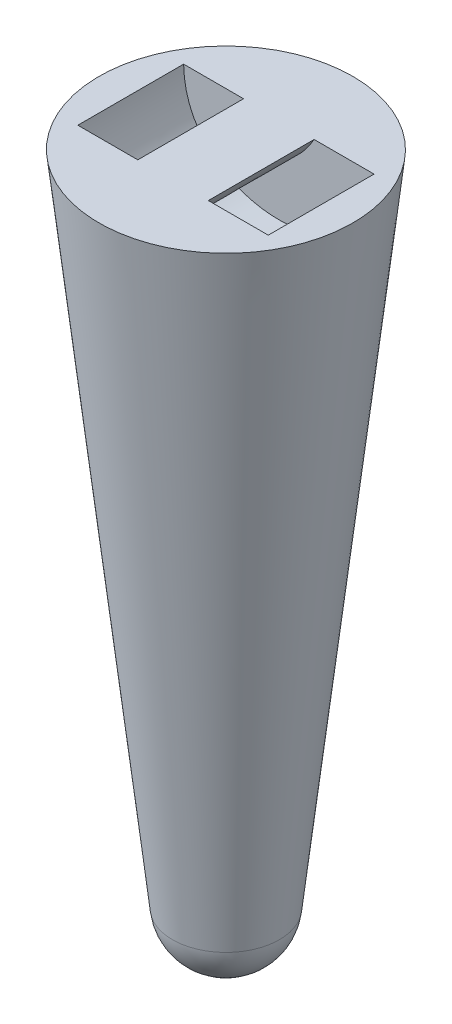
from build123d import *

# Parameters (mm, degrees)
ENL_V_MAT_EXTRU_1_DEPTH      = 7.5
ENL_V_MAT_EXTRU_1_DEPTH_BACK = 7.5
BOSS_EXTRU_1_REACH           = 27.5
ECHELLE1_SCALE               = 1.8


with BuildPart() as part:
    # Esquisse1 → R_volution1 (revolve)
    with BuildSketch(Plane.XY):
        with BuildLine():
            Line((0, 0), (0, 100))
            Line((0, 100), (-18, 100))
            Line((-18, 100), (-7.593007693, 6.792401612))
            ThreePointArc((-7.593007693, 6.792401612), (-5.093880777, 1.945904787), (0, 0))
        make_face()
    revolve(axis=Axis((0, 0, 0), (0, 1, 0)))

    # Esquisse2 → Enl_v. mat.-Extru.1 (cut, two sides)
    with BuildSketch(Plane.XY) as enl_v_mat_extru_1_sk:
        with BuildLine():
            Line((-13.5, 100), (13.5, 100))
            add(Edge.make_bspline(
                [(-13.5, 100), (-13.291113541, 83.520875666), (13.291113541, 83.520875666), (13.5, 100)],
                knots=[0, 0, 0, 0, 1, 1, 1, 1], degree=3))
        make_face()
    extrude(amount=ENL_V_MAT_EXTRU_1_DEPTH, mode=Mode.SUBTRACT)
    extrude(enl_v_mat_extru_1_sk.sketch, amount=-ENL_V_MAT_EXTRU_1_DEPTH_BACK, mode=Mode.SUBTRACT)

    # Esquisse3 → Boss.-Extru.1 (add, up to next)
    with BuildSketch(Plane.XY.offset(-7.5), mode=Mode.PRIVATE) as boss_extru_1_sk1:
        with BuildLine():
            Line((-5, 100), (5, 100))
            add(Edge.make_bspline(
                [(-5, 100), (0, 91.498247822), (5, 100)],
                knots=[0, 0, 0, 1, 1, 1], degree=2))
        make_face()
    boss_extru_1_tool1 = extrude(boss_extru_1_sk1.sketch, amount=BOSS_EXTRU_1_REACH, mode=Mode.PRIVATE) - part.part
    add(boss_extru_1_tool1.solids().sort_by_distance((0, 98.29965, -7.5))[0])


with BuildPart() as part_1:
    # Echelle1: scaled about (-4e-09, 62.219241992, 3e-09)
    add(part.part.scale(ECHELLE1_SCALE).moved(Location((3e-09, -49.775393594, -2e-09))))


solid = part_1.part
